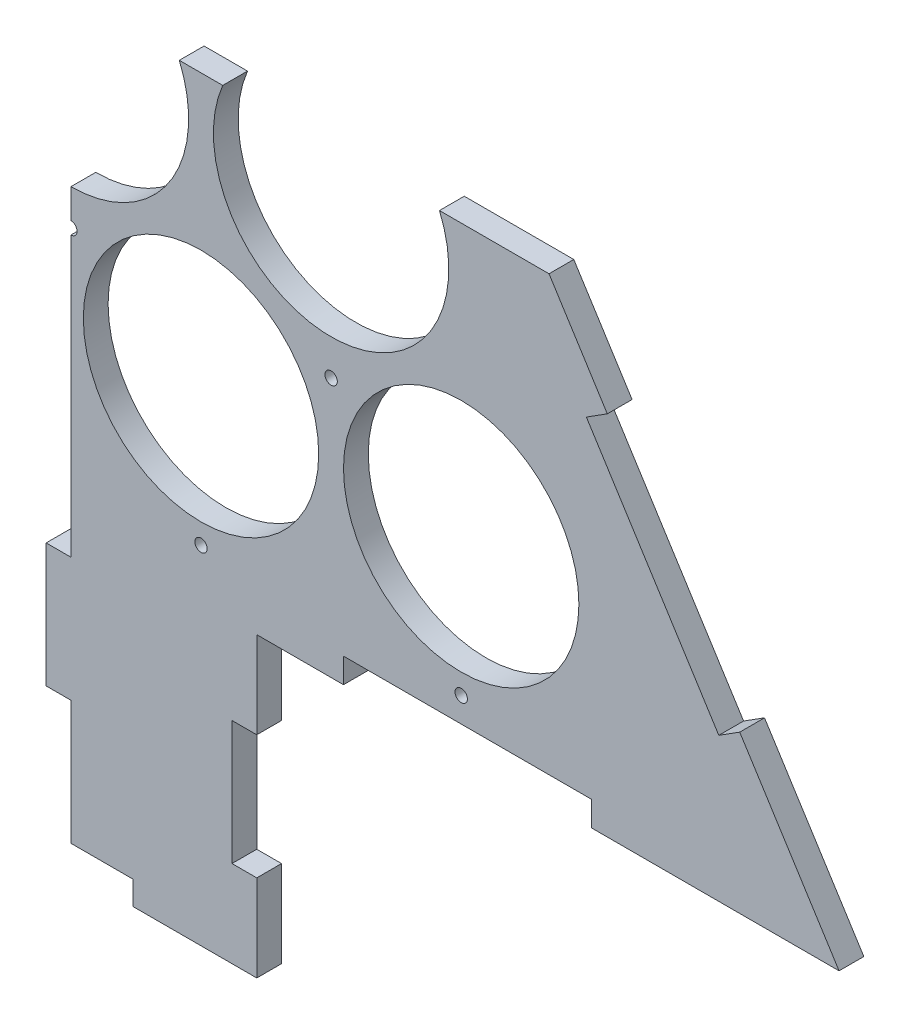
from build123d import *

# Parameters (mm, degrees)
ESQUISSE1_R             = 47.5
BOSS_EXTRU_1_DEPTH      = 10
ESQUISSE3_W             = 100
ESQUISSE3_H             = 10
ENL_V_MAT_EXTRU_1_DEPTH = 11
ESQUISSE4_R             = 2.5
ENL_V_MAT_EXTRU_2_DEPTH = 11
ESQUISSE6_W             = 150
ESQUISSE6_H             = 120
BOSS_EXTRU_2_DEPTH      = 10
ESQUISSE7_W             = 10
ESQUISSE7_H             = 50
ESQUISSE7_W_2           = 50
ESQUISSE7_H_2           = 9.570800355
ENL_V_MAT_EXTRU_3_DEPTH = 10
ENL_V_MAT_EXTRU_4_DEPTH = 10
ESQUISSE9_W             = 10
ESQUISSE9_H             = 50
BOSS_EXTRU_3_DEPTH      = 10


with BuildPart() as part:
    # Esquisse1 → Boss.-Extru.1 (new body)
    with BuildSketch(Plane.XY):
        Polygon((-310, -75.642859016), (0, 414.561180135), (310, -75.642859016), align=None)
        with Locations((-157.5, 0)):
            Circle(ESQUISSE1_R, mode=Mode.SUBTRACT)
        with Locations((-52.5, 0)):
            Circle(ESQUISSE1_R, mode=Mode.SUBTRACT)
        with Locations((52.5, 0)):
            Circle(ESQUISSE1_R, mode=Mode.SUBTRACT)
        with Locations((157.5, 0)):
            Circle(ESQUISSE1_R, mode=Mode.SUBTRACT)
        with Locations((-105, 90.932667397)):
            Circle(ESQUISSE1_R, mode=Mode.SUBTRACT)
        with Locations((0, 90.932667397)):
            Circle(ESQUISSE1_R, mode=Mode.SUBTRACT)
        with Locations((105, 90.932667397)):
            Circle(ESQUISSE1_R, mode=Mode.SUBTRACT)
        with Locations((-52.5, 181.865334795)):
            Circle(ESQUISSE1_R, mode=Mode.SUBTRACT)
        with Locations((52.5, 181.865334795)):
            Circle(ESQUISSE1_R, mode=Mode.SUBTRACT)
        with Locations((0, 272.798002192)):
            Circle(ESQUISSE1_R, mode=Mode.SUBTRACT)
    extrude(amount=BOSS_EXTRU_1_DEPTH)

    # Esquisse3 → Enlèv. mat.-Extru.1 (cut, through all)
    with BuildSketch(Plane.XY.offset(10)):
        Polygon((-269.913793103, -12.254405678), (-261.461999325, -17.599233264), (-208.013723463, 66.918704521), (-216.465517241, 72.263532107), align=None)
        Polygon((-181.724137931, 127.200191667), (-173.272344153, 121.855364081), (-119.82406829, 206.373301865), (-128.275862069, 211.718129452), align=None)
        Polygon((-93.534482759, 266.654789012), (-85.08268898, 261.309961425), (-31.634413118, 345.82789921), (-40.086206897, 351.172726796), align=None)
        Polygon((269.913793103, -12.254405678), (261.461999325, -17.599233264), (208.013723463, 66.918704521), (216.465517241, 72.263532107), align=None)
        Polygon((181.724137931, 127.200191667), (173.272344153, 121.855364081), (119.82406829, 206.373301865), (128.275862069, 211.718129452), align=None)
        Polygon((93.534482759, 266.654789012), (85.08268898, 261.309961425), (31.634413118, 345.82789921), (40.086206897, 351.172726796), align=None)
        with Locations((-160, -70.642859016)):
            Rectangle(ESQUISSE3_W, ESQUISSE3_H)
        with Locations((160, -70.642859016)):
            Rectangle(ESQUISSE3_W, ESQUISSE3_H)
    extrude(amount=-ENL_V_MAT_EXTRU_1_DEPTH, mode=Mode.SUBTRACT)

    # Esquisse4 → Enlèv. mat.-Extru.2 (cut, through all)
    with BuildSketch(Plane.XY.offset(10)):
        with Locations((-157.5, -55.642859016)):
            Circle(ESQUISSE4_R)
        with Locations((-52.5, -55.642859016)):
            Circle(ESQUISSE4_R)
        with Locations((52.5, -55.642859016)):
            Circle(ESQUISSE4_R)
        with Locations((157.5, -55.642859016)):
            Circle(ESQUISSE4_R)
        with Locations((-105, 29.047375097)):
            Circle(ESQUISSE4_R)
        with Locations((0, 29.047375097)):
            Circle(ESQUISSE4_R)
        with Locations((105, 29.047375097)):
            Circle(ESQUISSE4_R)
        with Locations((-52.5, 119.980042494)):
            Circle(ESQUISSE4_R)
        with Locations((52.5, 119.980042494)):
            Circle(ESQUISSE4_R)
        with Locations((0, 210.912709891)):
            Circle(ESQUISSE4_R)
    extrude(amount=-ENL_V_MAT_EXTRU_2_DEPTH, mode=Mode.SUBTRACT)

    # Esquisse6 → Boss.-Extru.2 (add)
    with BuildSketch(Plane.XY.offset(10)):
        with Locations((0, -135.642859016)):
            Rectangle(ESQUISSE6_W, ESQUISSE6_H)
    extrude(amount=-BOSS_EXTRU_2_DEPTH)

    # Esquisse7 → Enlèv. mat.-Extru.3 (cut)
    with BuildSketch(Plane.XY.offset(10)):
        with Locations((-70, -135.642859016)):
            Rectangle(ESQUISSE7_W, ESQUISSE7_H)
        with Locations((0, -190.857458839)):
            Rectangle(ESQUISSE7_W_2, ESQUISSE7_H_2)
        with Locations((70, -135.642859016)):
            Rectangle(ESQUISSE7_W, ESQUISSE7_H)
    extrude(amount=-ENL_V_MAT_EXTRU_3_DEPTH, mode=Mode.SUBTRACT)

    # Esquisse8 → Enlèv. mat.-Extru.4 (cut)
    with BuildSketch(Plane.XY.offset(10)):
        Polygon((0, -217.346828515), (0, 109.461180135), (292.569272736, 109.461180135), (292.569272736, 414.561180135), (0, 414.561180135), (-356.657737224, 414.561180135), (-356.657737224, -217.346828515), align=None)
    extrude(amount=-ENL_V_MAT_EXTRU_4_DEPTH, mode=Mode.SUBTRACT)

    # Esquisse9 → Boss.-Extru.3 (add)
    with BuildSketch(Plane.XY.offset(10)):
        with Locations((-5, -111.072058661)):
            Rectangle(ESQUISSE9_W, ESQUISSE9_H)
    extrude(amount=-BOSS_EXTRU_3_DEPTH)


solid = part.part
